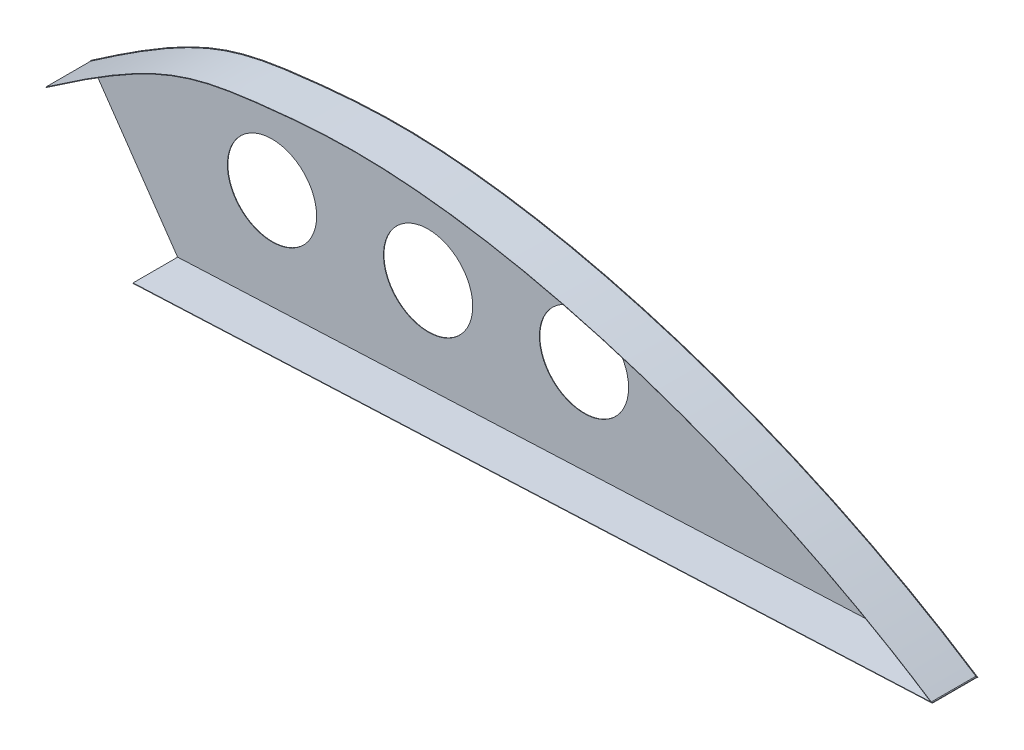
from build123d import *

# Parameters (mm, degrees)
SKETCH1_R           = 10
BOSS_EXTRUDE1_DEPTH = 0.1
BOSS_EXTRUDE2_DEPTH = 10
BOSS_EXTRUDE5_DEPTH = 10


with BuildPart() as part:
    # Sketch1 → Boss-Extrude1 (new body)
    with BuildSketch(Plane.XY):
        with BuildLine():
            Line((-1743.607960183, 593.830470178), (-1723.97557604, 565.354199265))
            Line((-1723.97557604, 565.354199265), (-1544.649956659, 573.44143308))
            add(Edge.make_bspline(
                [(-1743.607960183, 593.830470178), (-1719.507904213, 610.537812828), (-1709.389541143, 613.399774739), (-1646.280289738, 619.241808081), (-1585.716648888, 600.423930323), (-1544.649956659, 573.44143308)],
                knots=[0, 0, 0, 0, 0.320554642, 0.420554642, 1, 1, 1, 1], degree=3))
        make_face()
        with Locations((-1632.906290904, 590.670757295)):
            Circle(SKETCH1_R, mode=Mode.SUBTRACT)
        with Locations((-1667.865738011, 588.986400452)):
            Circle(SKETCH1_R, mode=Mode.SUBTRACT)
        with Locations((-1702.865738011, 588.986400452)):
            Circle(SKETCH1_R, mode=Mode.SUBTRACT)
    extrude(amount=BOSS_EXTRUDE1_DEPTH)

    # Sketch2 → Boss-Extrude2 (add)
    with BuildSketch(Plane.XY.offset(0.1)):
        Polygon((-1724.027783053, 565.451946471), (-1723.97557604, 565.354199265), (-1544.79832648, 573.434741892), (-1544.802831705, 573.534640355), align=None)
    extrude(amount=BOSS_EXTRUDE2_DEPTH)

    # Sketch3 → Boss-Extrude5 (add)
    with BuildSketch(Plane.XY.offset(0.1)):
        with BuildLine():
            Line((-1545.023079711, 573.566578824), (-1545.182742706, 573.5515561))
            add(Edge.make_bspline(
                [(-1545.182742706, 573.5515561), (-1547.367111706, 574.980268212), (-1551.810044118, 577.785328256), (-1560.965598012, 583.174479228), (-1572.795764, 589.430500324), (-1587.376218754, 596.094131565), (-1607.088908765, 603.794197945), (-1626.860275971, 609.633108879), (-1645.984019518, 613.443251497), (-1659.830715168, 615.239913168), (-1672.989792243, 615.951202382), (-1683.282773373, 615.549802626), (-1690.803354798, 614.881158472), (-1697.680820628, 614.1264693), (-1704.980899474, 613.117091179), (-1711.55998554, 611.460964287), (-1716.962589709, 609.43710742), (-1721.23073898, 607.488971473), (-1725.859262309, 605.030940979), (-1730.13578168, 602.491531609), (-1733.880880623, 600.125360581), (-1736.867805363, 598.174714985), (-1739.526085034, 596.39020329), (-1741.749970087, 594.871411779), (-1742.918244581, 594.065255562), (-1743.494013607, 593.66610419)],
                knots=[0.001987871, 0.001987871, 0.001987871, 0.001987871, 0.032699504, 0.063902746, 0.126309229, 0.188715713, 0.251122197, 0.375935164, 0.438341647, 0.500748131, 0.563154615, 0.625561098, 0.65676434, 0.687967582, 0.750374066, 0.812780549, 0.843983791, 0.875187033, 0.906390275, 0.937593516, 0.953195137, 0.968796758, 0.984398379, 0.99219919, 1, 1, 1, 1], degree=3))
            Line((-1743.494013607, 593.66610419), (-1743.550986895, 593.748287184))
            add(Edge.make_bspline(
                [(-1545.023079711, 573.566578824), (-1580.385570882, 596.721777486), (-1623.540098869, 611.77846709), (-1664.058944494, 615.565415197), (-1668.460623745, 615.803565887), (-1674.850272895, 615.874635067), (-1676.946082289, 615.848904453), (-1681.051562144, 615.71013567), (-1685.067312648, 615.488156686), (-1688.83699666, 615.1571463), (-1692.450372149, 614.800321889), (-1694.177045989, 614.610346383), (-1699.085739343, 614.035305054), (-1702.019101267, 613.629485697), (-1710.378502815, 612.027658053), (-1715.364224243, 610.448022257), (-1727.252760657, 604.56560412), (-1734.155086468, 600.261986909), (-1743.550986895, 593.748287184)],
                knots=[0.001496262, 0.001496262, 0.001496262, 0.001496262, 0.5, 0.5, 0.5625, 0.5625, 0.59375, 0.59375, 0.625, 0.65625, 0.65625, 0.6875, 0.6875, 0.75, 0.75, 0.875, 0.875, 1, 1, 1, 1], degree=3))
        make_face()
    extrude(amount=BOSS_EXTRUDE5_DEPTH)


solid = part.part
